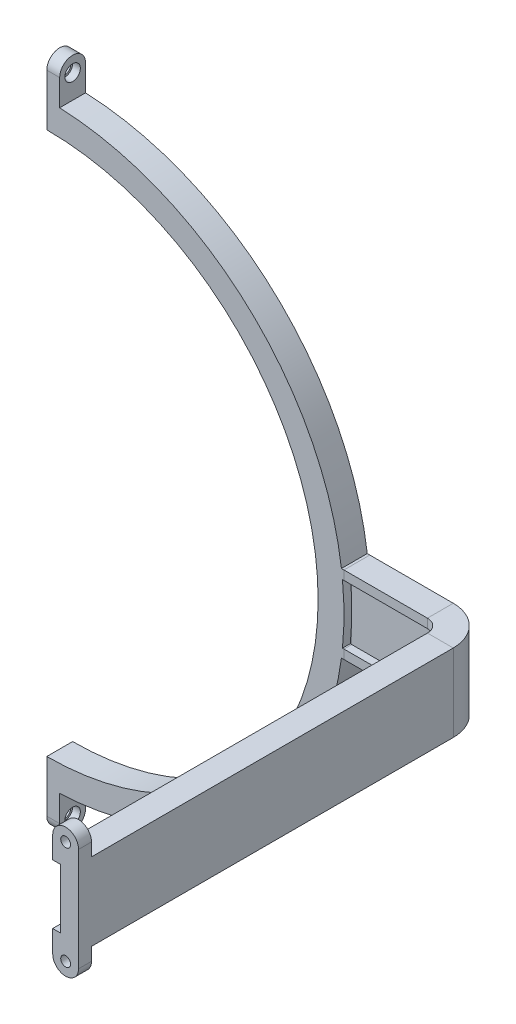
from build123d import *

# Parameters (mm, degrees)
SKETCH_1_R                = 115
SKETCH_1_R_2              = 105
EXTRUDE_1_DEPTH           = 5
SKETCH_4_R                = 2.5
CUT_EXTRUDE_1_DEPTH       = 33.934862746
EXTRUDE_2_DEPTH           = 5
HOLE_WIZARD_1_D           = 4.5
HOLE_WIZARD_1_CBORE_D     = 6
HOLE_WIZARD_1_CBORE_DEPTH = 3
SKETCH_9_R                = 2.25
SKETCH_9_R_2              = 1.9
EXTRUDE_3_DEPTH           = 5
EXTRUDE_4_DEPTH           = 5
HOLE_WIZARD_2_D           = 4.5
HOLE_WIZARD_2_CBORE_D     = 6
HOLE_WIZARD_2_CBORE_DEPTH = 3
SKETCH_13_R               = 2.25
SKETCH_13_R_2             = 1.9
EXTRUDE_5_DEPTH           = 5
SKETCH_14_W               = 562.038590931
SKETCH_14_H               = 462.09177453
CUT_EXTRUDE_4_DEPTH       = 163.29776757
SKETCH_15_W               = 637.223239982
SKETCH_15_H               = 375.31186697
CUT_EXTRUDE_5_DEPTH       = 202.710100717


with BuildPart() as part:
    # 草图1 → 凸台-拉伸1 (new body, symmetric)
    with BuildSketch(Plane.XY):
        Circle(SKETCH_1_R)
        Circle(SKETCH_1_R_2, mode=Mode.SUBTRACT)
    extrude(amount=EXTRUDE_1_DEPTH, both=True)

    # 扫描1: sweep along a path in 草图2
    with BuildLine(Plane(origin=(0, 0, 0), x_dir=(1, 0, 0), z_dir=(0, 1, 0))) as sweep_1_path:
        Line((-130, -355), (-156.694693778, -281.656931626))
        ThreePointArc((-156.694693778, -281.656931626), (-157.1458451, -279.97321197), (-157.29776757, -278.236730193))
        Line((-157.29776757, -278.236730193), (-157.29776757, -10))
        ThreePointArc((-157.29776757, -10), (-154.368835382, -2.928932188), (-147.29776757, 0))
        Line((-147.29776757, 0), (-115, 0))
        Line((-115, 0), (-106.681302201, 0))
    # 草图3 → 扫描1 (sweep)
    with BuildSketch(Plane(origin=(-130, 0, 355), x_dir=(0.939692621, 0, -0.342020143), z_dir=(0.342020143, 0, 0.939692621))):
        Polygon((-5, -15), (5, -15), (5, -11.5), (2, -11.5), (2, 11.5), (5, 11.5), (5, 15), (-5, 15), align=None)
    sweep_1 = sweep(path=sweep_1_path.line)

    # 草图4 → 切除-拉伸1 (cut, through all)
    with BuildSketch(Plane(origin=(-227.008304281, 0, 82.624265689), x_dir=(-0.342020143, 0, -0.939692621), z_dir=(0.939692621, 0, -0.342020143))):
        with Locations((-274.128261747, 6.75)):
            Circle(SKETCH_4_R)
        with Locations((-274.128261747, -6.75)):
            Circle(SKETCH_4_R)
    cut_extrude_1 = extrude(amount=-CUT_EXTRUDE_1_DEPTH, mode=Mode.SUBTRACT)

    # 镜向1: 扫描1, 切除-拉伸1 across plane
    add(sweep_1.mirror(Plane(origin=(0, 0, 0), x_dir=(0, 0, 1), z_dir=(1, 0, 0))))
    add(cut_extrude_1.mirror(Plane(origin=(0, 0, 0), x_dir=(0, 0, 1), z_dir=(1, 0, 0))), mode=Mode.SUBTRACT)

    # 草图6 → 凸台-拉伸2 (add, symmetric)
    with BuildSketch(Plane(origin=(0, 0, 0), x_dir=(0, 0, -1), z_dir=(1, 0, 0))):
        with BuildLine():
            Line((-5, 115), (-5, 125))
            ThreePointArc((-5, 125), (0, 130), (5, 125))
            Line((5, 125), (5, 115))
            Line((5, 115), (5, 112.136445143))
            Line((5, 112.136445143), (-5, 112.136445143))
            Line((-5, 112.136445143), (-5, 115))
        make_face()
    extrude_2 = extrude(amount=EXTRUDE_2_DEPTH, both=True)

    # 镜向2: 凸台-拉伸2 across plane
    add(extrude_2.mirror(Plane.ZX))

    # 孔1 (through all)
    with Locations(Plane(origin=(5, 0, 0), x_dir=(0, 0, -1), z_dir=(1, 0, 0))):
        with Locations((0, 124.156343107), (0, -125)):
            CounterBoreHole(HOLE_WIZARD_1_D / 2, HOLE_WIZARD_1_CBORE_D / 2, HOLE_WIZARD_1_CBORE_DEPTH)

    # 草图9 → 凸台-拉伸3 (add)
    with BuildSketch(Plane.ZY.offset(5)):
        with Locations((0, 124.156343107)):
            Circle(SKETCH_9_R)
        with Locations((0, 124.156343107)):
            Circle(SKETCH_9_R_2, mode=Mode.SUBTRACT)
        with Locations((0, -125)):
            Circle(SKETCH_9_R)
        with Locations((0, -125)):
            Circle(SKETCH_9_R_2, mode=Mode.SUBTRACT)
    extrude(amount=-EXTRUDE_3_DEPTH)

    # 草图10 → 凸台-拉伸4 (add, symmetric)
    with BuildSketch(Plane.XY.offset(155)):
        with BuildLine():
            Line((-162.29776757, 15), (-152.29776757, 15))
            Line((-152.29776757, 15), (-152.29776757, 20))
            ThreePointArc((-152.29776757, 20), (-157.29776757, 25), (-162.29776757, 20))
            Line((-162.29776757, 20), (-162.29776757, 15))
        make_face()
        with BuildLine():
            Line((-152.29776757, -15), (-152.29776757, -20))
            ThreePointArc((-152.29776757, -20), (-157.29776757, -25), (-162.29776757, -20))
            Line((-162.29776757, -20), (-162.29776757, -15))
            Line((-162.29776757, -15), (-152.29776757, -15))
        make_face()
        with BuildLine():
            Line((162.29776757, -15), (152.29776757, -15))
            Line((152.29776757, -15), (152.29776757, -20))
            ThreePointArc((152.29776757, -20), (157.29776757, -25), (162.29776757, -20))
            Line((162.29776757, -20), (162.29776757, -15))
        make_face()
        with BuildLine():
            Line((152.29776757, 15), (152.29776757, 20))
            ThreePointArc((152.29776757, 20), (157.29776757, 25), (162.29776757, 20))
            Line((162.29776757, 20), (162.29776757, 15))
            Line((162.29776757, 15), (152.29776757, 15))
        make_face()
    extrude(amount=EXTRUDE_4_DEPTH, both=True)

    # 孔2 (through all)
    with Locations(Plane.XY.offset(160)):
        with Locations((-157.29776757, 20), (-157.29776757, -20), (157.29776757, 20), (157.29776757, -20)):
            CounterBoreHole(HOLE_WIZARD_2_D / 2, HOLE_WIZARD_2_CBORE_D / 2, HOLE_WIZARD_2_CBORE_DEPTH)

    # 草图13 → 凸台-拉伸5 (add)
    with BuildSketch(Plane(origin=(0, 0, 150), x_dir=(-1, 0, 0), z_dir=(0, 0, -1))):
        with Locations((-157.29776757, 20)):
            Circle(SKETCH_13_R)
        with Locations((-157.29776757, 20)):
            Circle(SKETCH_13_R_2, mode=Mode.SUBTRACT)
        with Locations((-157.29776757, -20)):
            Circle(SKETCH_13_R)
        with Locations((-157.29776757, -20)):
            Circle(SKETCH_13_R_2, mode=Mode.SUBTRACT)
        with Locations((157.29776757, -20)):
            Circle(SKETCH_13_R)
        with Locations((157.29776757, -20)):
            Circle(SKETCH_13_R_2, mode=Mode.SUBTRACT)
        with Locations((157.29776757, 20)):
            Circle(SKETCH_13_R)
        with Locations((157.29776757, 20)):
            Circle(SKETCH_13_R_2, mode=Mode.SUBTRACT)
    extrude(amount=-EXTRUDE_5_DEPTH)

    # 草图14 → 切除-拉伸4 (cut, through all)
    with BuildSketch(Plane(origin=(0, 0, 0), x_dir=(0, 0, -1), z_dir=(1, 0, 0))):
        with Locations((-153.139864812, -31.152254463)):
            Rectangle(SKETCH_14_W, SKETCH_14_H)
    extrude(amount=-CUT_EXTRUDE_4_DEPTH, mode=Mode.SUBTRACT)

    # 草图15 → 切除-拉伸5 (cut, through all)
    with BuildSketch(Plane.XY.offset(155)):
        Rectangle(SKETCH_15_W, SKETCH_15_H)
    extrude(amount=CUT_EXTRUDE_5_DEPTH, mode=Mode.SUBTRACT)


solid = part.part
